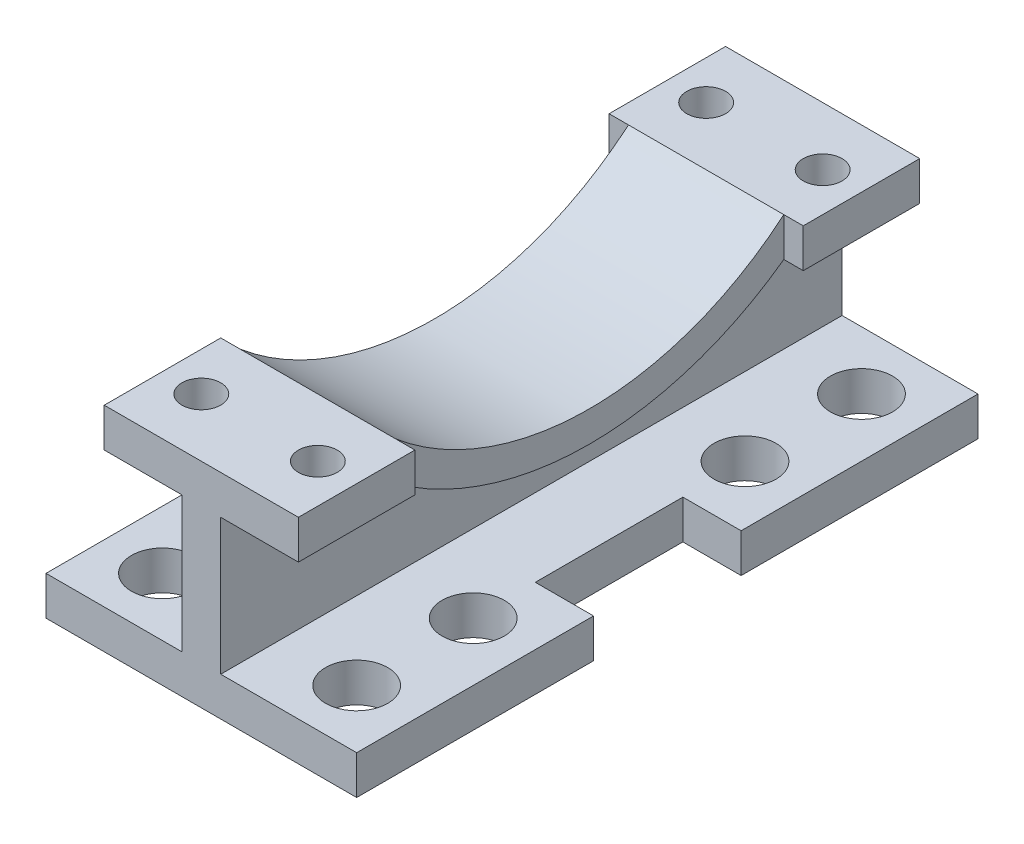
from build123d import *

# Parameters (mm, degrees)
SKETCH1_R           = 8
BOSS_EXTRUDE1_DEPTH = 10
BOSS_EXTRUDE2_DEPTH = 5
SKETCH7_W           = 50
SKETCH7_H           = 30
SKETCH7_R           = 5
BOSS_EXTRUDE3_DEPTH = 10
BOSS_EXTRUDE5_DEPTH = 20
CUT_EXTRUDE1_DEPTH  = 20


with BuildPart() as part:
    # Sketch1 → Boss-Extrude1 (new body)
    with BuildSketch(Plane(origin=(0, 0, 0), x_dir=(1, 0, 0), z_dir=(0, 1, 0))):
        Polygon((80, 160), (0, 160), (0, 99), (15, 99), (15, 61), (0, 61), (0, 0), (80, 0), (80, 61), (65, 61), (65, 99), (80, 99), align=None)
        with Locations((15, 15)):
            Circle(SKETCH1_R, mode=Mode.SUBTRACT)
        with Locations((15, 45)):
            Circle(SKETCH1_R, mode=Mode.SUBTRACT)
        with Locations((65, 15)):
            Circle(SKETCH1_R, mode=Mode.SUBTRACT)
        with Locations((65, 45)):
            Circle(SKETCH1_R, mode=Mode.SUBTRACT)
        with Locations((15, 115)):
            Circle(SKETCH1_R, mode=Mode.SUBTRACT)
        with Locations((15, 145)):
            Circle(SKETCH1_R, mode=Mode.SUBTRACT)
        with Locations((65, 115)):
            Circle(SKETCH1_R, mode=Mode.SUBTRACT)
        with Locations((65, 145)):
            Circle(SKETCH1_R, mode=Mode.SUBTRACT)
    extrude(amount=BOSS_EXTRUDE1_DEPTH)

    # Sketch2 → Boss-Extrude2 (add, symmetric)
    with BuildSketch(Plane(origin=(40, 0, 0), x_dir=(0, 0, -1), z_dir=(1, 0, 0))):
        Polygon((160, 10), (99, 10), (61, 10), (0, 10), (0, 45), (160, 45), align=None)
    extrude(amount=BOSS_EXTRUDE2_DEPTH, both=True)

    # Sketch7 → Boss-Extrude3 (add)
    with BuildSketch(Plane(origin=(0, 45, 0), x_dir=(-1, 0, 0), z_dir=(0, -1, 0))):
        with Locations((-40, 15)):
            Rectangle(SKETCH7_W, SKETCH7_H)
        with Locations((-55, 15)):
            Circle(SKETCH7_R, mode=Mode.SUBTRACT)
        with Locations((-25, 15)):
            Circle(SKETCH7_R, mode=Mode.SUBTRACT)
        with Locations((-40, 145)):
            Rectangle(SKETCH7_W, SKETCH7_H)
        with Locations((-25, 145)):
            Circle(SKETCH7_R, mode=Mode.SUBTRACT)
        with Locations((-55, 145)):
            Circle(SKETCH7_R, mode=Mode.SUBTRACT)
    extrude(amount=-BOSS_EXTRUDE3_DEPTH)

    # Sketch12 → Boss-Extrude5 (add, symmetric)
    with BuildSketch(Plane(origin=(40, 0, 0), x_dir=(0, 0, -1), z_dir=(1, 0, 0))):
        with BuildLine():
            ThreePointArc((30, 45), (80, 28.829043194), (130, 45))
            Line((130, 45), (114.867292292, 45))
            ThreePointArc((114.867292292, 45), (80, 36.713596412), (45.132707708, 45))
            Line((45.132707708, 45), (30, 45))
        make_face()
        with BuildLine():
            Line((30, 55), (30, 45))
            Line((30, 45), (45.132707708, 45))
            ThreePointArc((45.132707708, 45), (37.272791745, 49.555761041), (30, 55))
        make_face()
        with BuildLine():
            Line((114.867292292, 45), (130, 45))
            Line((130, 45), (130, 55))
            ThreePointArc((130, 55), (122.727208255, 49.555761041), (114.867292292, 45))
        make_face()
    extrude(amount=BOSS_EXTRUDE5_DEPTH, both=True)

    # Sketch10 → Cut-Extrude1 (cut, symmetric)
    with BuildSketch(Plane(origin=(45, 0, 0), x_dir=(0, 0, -1), z_dir=(1, 0, 0))):
        with BuildLine():
            Line((114.867292292, 45), (45.132707708, 45))
            ThreePointArc((45.132707708, 45), (80, 36.713596412), (114.867292292, 45))
        make_face()
    extrude(amount=CUT_EXTRUDE1_DEPTH, both=True, mode=Mode.SUBTRACT)


solid = part.part
